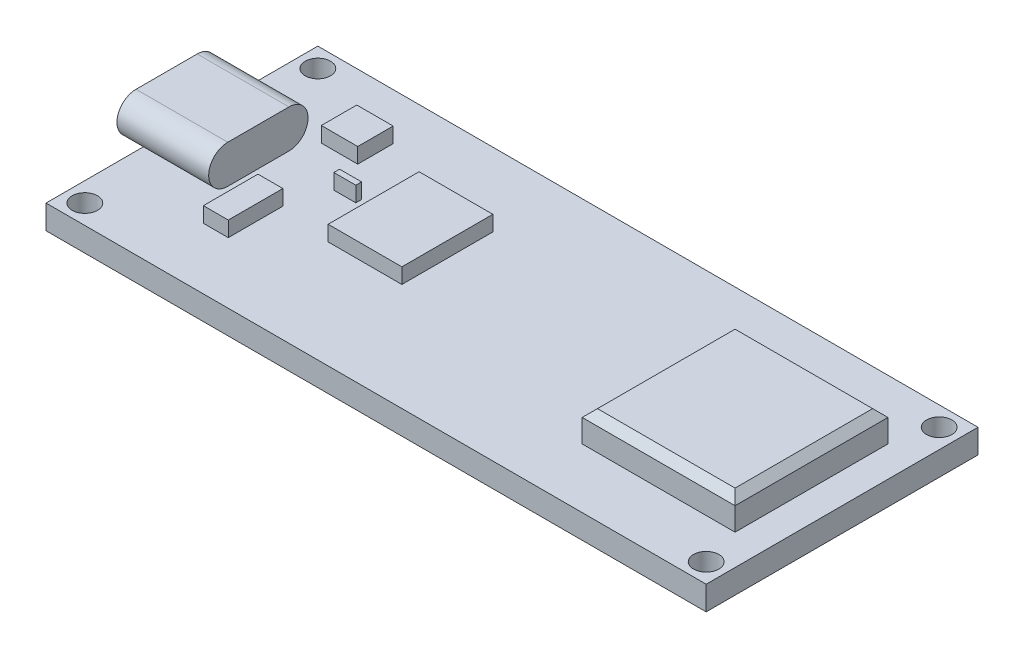
from build123d import *

# Parameters (mm, degrees)
SKETCH1_W                = 43.18
SKETCH1_H                = 17.78
SKETCH1_R                = 0.83
BOSS_EXTRUDE1_DEPTH      = 1.57
SKETCH2_W                = 10
SKETCH2_H                = 10
BOSS_EXTRUDE2_DEPTH      = 2
CHAMFER1_SIZE            = 0.5
BOSS_EXTRUDE3_DEPTH      = 1
BOSS_EXTRUDE3_DEPTH_BACK = 5
SKETCH4_W                = 2.380224585
SKETCH4_H                = 2.317587096
SKETCH4_W_2              = 1.628574716
SKETCH4_H_2              = 3.570336877
SKETCH4_W_3              = 4.823086659
SKETCH4_H_3              = 5.950561462
SKETCH4_W_4              = 1.440662249
SKETCH4_H_4              = 0.375824935
BOSS_EXTRUDE4_DEPTH      = 1


with BuildPart() as part:
    # Sketch1 → Boss-Extrude1 (new body)
    with BuildSketch(Plane(origin=(0, 0, 0), x_dir=(1, 0, 0), z_dir=(0, 1, 0))):
        Rectangle(SKETCH1_W, SKETCH1_H)
        with Locations((-20.32, 7.62)):
            Circle(SKETCH1_R, mode=Mode.SUBTRACT)
        with Locations((20.32, 7.62)):
            Circle(SKETCH1_R, mode=Mode.SUBTRACT)
        with Locations((20.32, -7.62)):
            Circle(SKETCH1_R, mode=Mode.SUBTRACT)
        with Locations((-20.32, -7.62)):
            Circle(SKETCH1_R, mode=Mode.SUBTRACT)
    extrude(amount=BOSS_EXTRUDE1_DEPTH)

    # Sketch2 → Boss-Extrude2 (add)
    with BuildSketch(Plane(origin=(0, 1.57, 0), x_dir=(1, 0, 0), z_dir=(0, 1, 0))):
        with Locations((14.59, 0)):
            Rectangle(SKETCH2_W, SKETCH2_H)
    extrude(amount=BOSS_EXTRUDE2_DEPTH)

    # Chamfer1
    chamfer1_edges = [part.edges().sort_by_distance(p)[0] for p in [
        (9.59, 3.57, 0),
        (14.59, 3.57, 5),
        (19.59, 3.57, 0),
        (14.59, 3.57, -5),
    ]]
    chamfer(chamfer1_edges, length=CHAMFER1_SIZE)

    # Sketch3 → Boss-Extrude3 (add, two sides)
    with BuildSketch(Plane.ZY.offset(21.59)) as boss_extrude3_sk:
        with BuildLine():
            Line((-2, 4.07), (2, 4.07))
            ThreePointArc((2, 4.07), (3.25, 2.82), (2, 1.57))
            Line((2, 1.57), (-2, 1.57))
            ThreePointArc((-2, 1.57), (-3.25, 2.82), (-2, 4.07))
        make_face()
    extrude(amount=BOSS_EXTRUDE3_DEPTH)
    extrude(boss_extrude3_sk.sketch, amount=-BOSS_EXTRUDE3_DEPTH_BACK)

    # Sketch4 → Boss-Extrude4 (add)
    with BuildSketch(Plane(origin=(0, 1.57, 0), x_dir=(1, 0, 0), z_dir=(0, 1, 0))):
        with Locations((-14.788997849, 4.667413541)):
            Rectangle(SKETCH4_W, SKETCH4_H)
        with Locations((-14.480791416, -3.105550682)):
            Rectangle(SKETCH4_W_2, SKETCH4_H_2)
        with Locations((-7.750249949, 1.110525399)):
            Rectangle(SKETCH4_W_3, SKETCH4_H_3)
        with Locations((-12.189542052, 1.441582853)):
            Rectangle(SKETCH4_W_4, SKETCH4_H_4)
    extrude(amount=BOSS_EXTRUDE4_DEPTH)


solid = part.part
